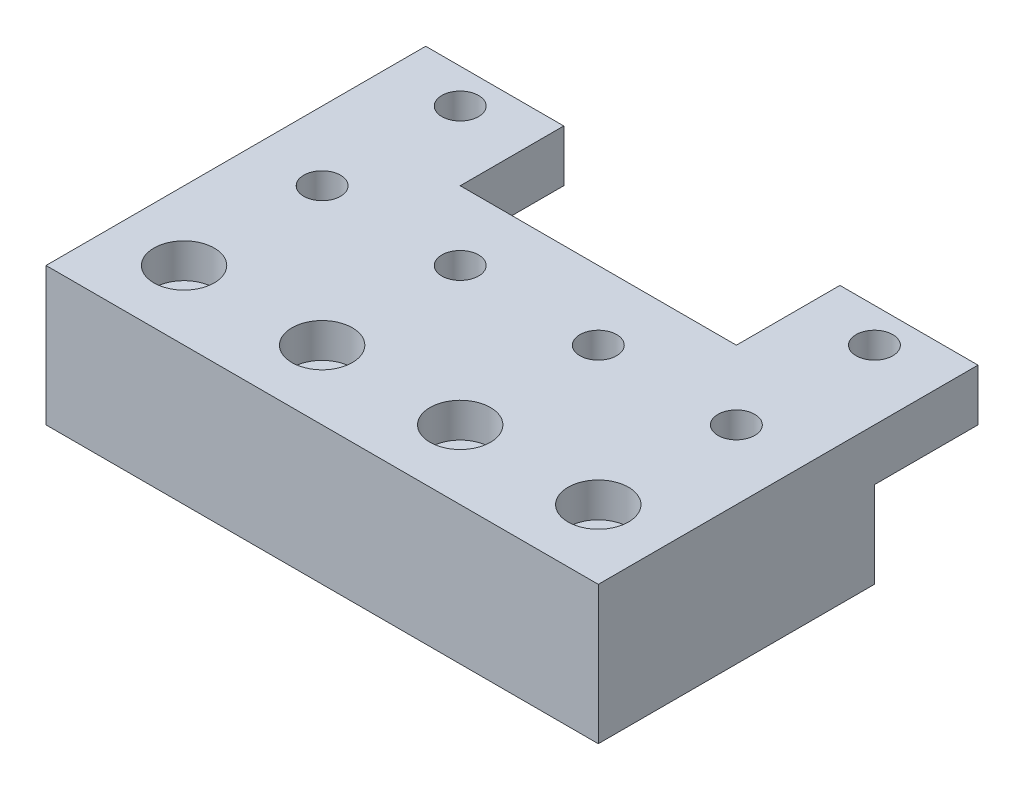
from build123d import *

# Parameters (mm, degrees)
SKETCH1_W                                        = 101.6
SKETCH1_H                                        = 50.8
BOSS_EXTRUDE1_DEPTH                              = 25.4
CBORE_FOR_1_4_SOCKET_HEAD_CAP_SCREW1_D           = 6.7564
CBORE_FOR_1_4_SOCKET_HEAD_CAP_SCREW1_CBORE_D     = 11.1125
CBORE_FOR_1_4_SOCKET_HEAD_CAP_SCREW1_CBORE_DEPTH = 6.35
LPATTERN1_COUNT                                  = 4
LPATTERN1_PITCH                                  = 25.4
F_1_4_CLEARANCE_HOLE1_D                          = 6.7564
LPATTERN2_COUNT                                  = 4
LPATTERN2_PITCH                                  = 25.4
SKETCH7_W                                        = 101.6
SKETCH7_H                                        = 9.525
BOSS_EXTRUDE2_DEPTH                              = 19.05
SKETCH8_W                                        = 50.8
SKETCH8_H                                        = 9.525
CUT_EXTRUDE1_DEPTH                               = 19.05
LPATTERN3_COUNT                                  = 2
LPATTERN3_PITCH                                  = 25.4
LPATTERN4_COPY_1_D                               = 6.7564
LPATTERN4_COPY_2_D                               = 6.7564


with BuildPart() as part:
    # Sketch1 → Boss-Extrude1 (new body)
    with BuildSketch(Plane(origin=(0, 0, 0), x_dir=(1, 0, 0), z_dir=(0, 1, 0))):
        with Locations((50.8, 25.4)):
            Rectangle(SKETCH1_W, SKETCH1_H)
    extrude(amount=BOSS_EXTRUDE1_DEPTH)

    # CBORE for 1/4 Socket Head Cap Screw1 (through all)
    with Locations(Plane(origin=(0, 25.4, 0), x_dir=(-1, 0, 0), z_dir=(0, 1, 0))):
        with Locations((-12.7, -12.7)):
            cbore_for_1_4_socket_head_cap_screw1 = CounterBoreHole(CBORE_FOR_1_4_SOCKET_HEAD_CAP_SCREW1_D / 2, CBORE_FOR_1_4_SOCKET_HEAD_CAP_SCREW1_CBORE_D / 2, CBORE_FOR_1_4_SOCKET_HEAD_CAP_SCREW1_CBORE_DEPTH)

    # LPattern1: CBORE for 1/4 Socket Head Cap Screw1 ×4
    with Locations(*[(i * LPATTERN1_PITCH, 0, 0) for i in range(1, LPATTERN1_COUNT)]):
        add(cbore_for_1_4_socket_head_cap_screw1, mode=Mode.SUBTRACT)

    # 1/4 Clearance Hole1 (through all)
    with Locations(Plane(origin=(0, 25.4, 0), x_dir=(-1, 0, 0), z_dir=(0, 1, 0))):
        with Locations((-12.7, -38.1)):
            f_1_4_clearance_hole1 = Hole(F_1_4_CLEARANCE_HOLE1_D / 2)

    # LPattern2: 1/4 Clearance Hole1 ×4
    with Locations(*[(i * LPATTERN2_PITCH, 0, 0) for i in range(1, LPATTERN2_COUNT)]):
        add(f_1_4_clearance_hole1, mode=Mode.SUBTRACT)

    # Sketch7 → Boss-Extrude2 (add)
    with BuildSketch(Plane(origin=(0, 0, -50.8), x_dir=(-1, 0, 0), z_dir=(0, 0, -1))):
        with Locations((-50.8, 20.6375)):
            Rectangle(SKETCH7_W, SKETCH7_H)
    extrude(amount=BOSS_EXTRUDE2_DEPTH)

    # Sketch8 → Cut-Extrude1 (cut)
    with BuildSketch(Plane(origin=(0, 0, -69.85), x_dir=(-1, 0, 0), z_dir=(0, 0, -1))):
        with Locations((-50.8, 20.6375)):
            Rectangle(SKETCH8_W, SKETCH8_H)
    extrude(amount=-CUT_EXTRUDE1_DEPTH, mode=Mode.SUBTRACT)

    # LPattern3: 1/4 Clearance Hole1 ×2
    with Locations(*[(0, 0, -i * LPATTERN3_PITCH) for i in range(1, LPATTERN3_COUNT)]):
        add(f_1_4_clearance_hole1, mode=Mode.SUBTRACT)

    # LPattern4 copy 1 (through all)
    with Locations(Plane(origin=(76.2, 25.4, -25.4), x_dir=(-1, 0, 0), z_dir=(0, 1, 0))):
        with Locations((-12.7, -38.1)):
            Hole(LPATTERN4_COPY_1_D / 2)

    # LPattern4 copy 2 (through all)
    with Locations(Plane(origin=(76.2, 25.4, 0), x_dir=(-1, 0, 0), z_dir=(0, 1, 0))):
        with Locations((-12.7, -38.1)):
            Hole(LPATTERN4_COPY_2_D / 2)


solid = part.part
